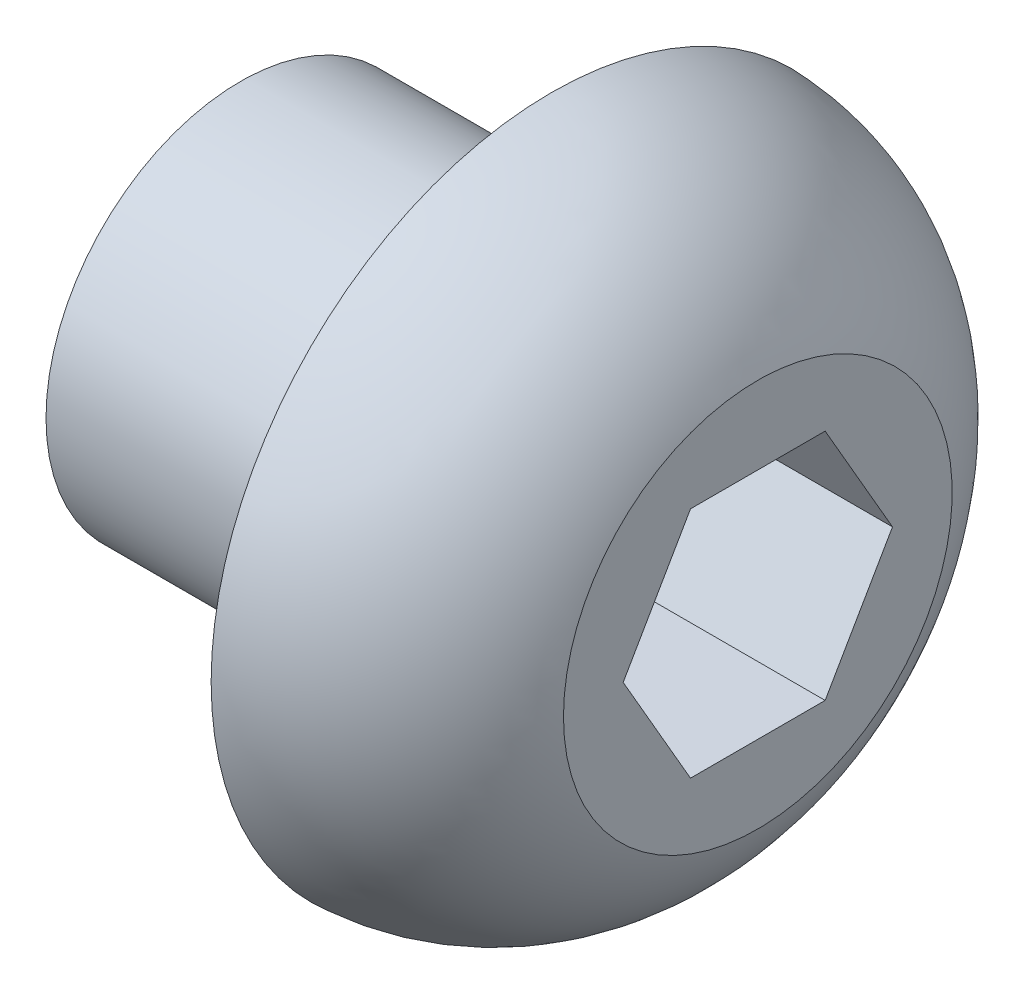
from build123d import *

# Parameters (mm, degrees)
HEX_2_DEPTH = 3.81


with BuildPart() as part:
    # Sketch1 → Base-Revolve (revolve)
    with BuildSketch(Plane.XY):
        with BuildLine():
            Line((0, 0), (0, 3.96875))
            Line((0, 3.96875), (6.35, 3.96875))
            Line((6.35, 3.96875), (6.35, 6.9469))
            ThreePointArc((6.35, 6.9469), (8.893583592, 6.074231621), (10.5664, 3.96875))
            Line((10.5664, 3.96875), (10.5664, 0))
            Line((10.5664, 0), (0, 0))
        make_face()
    revolve(axis=Axis((-7.109595529, 0, 0), (1, 0, 0)))

    # Sketch2 → HEX 2 (cut)
    with BuildSketch(Plane(origin=(10.5664, 0, 0), x_dir=(0, 0, -1), z_dir=(1, 0, 0))):
        Polygon((2.749630657, 0), (1.374815329, 2.38125), (-1.374815329, 2.38125), (-2.749630657, 0), (-1.374815329, -2.38125), (1.374815329, -2.38125), align=None)
    extrude(amount=-HEX_2_DEPTH, mode=Mode.SUBTRACT)


solid = part.part
